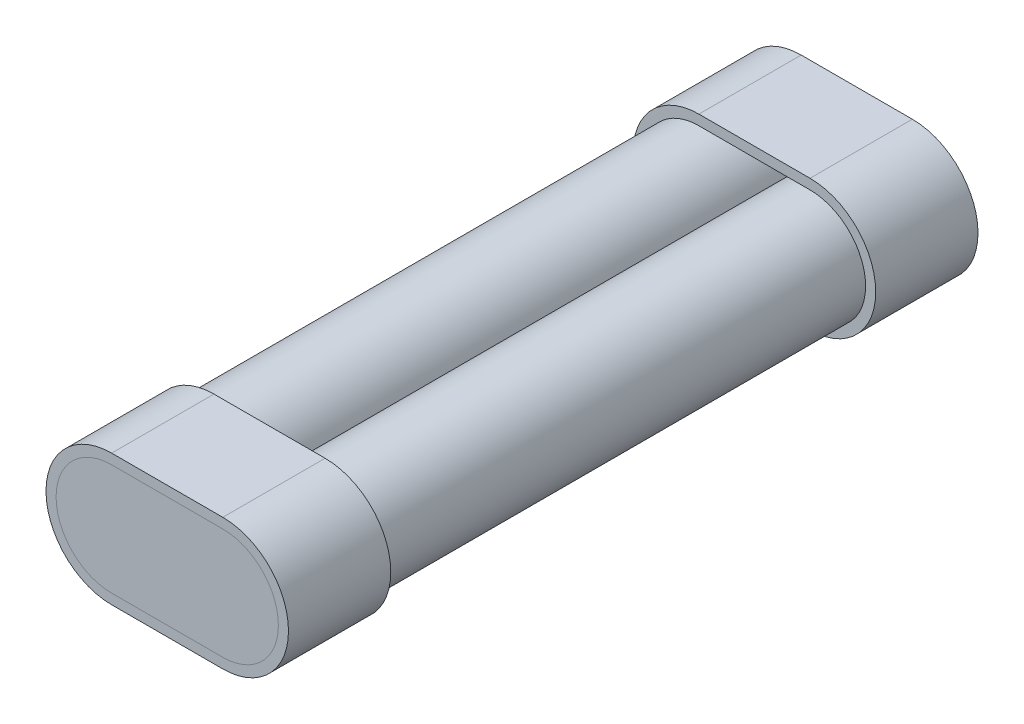
from build123d import *

# Parameters (mm, degrees)
ESQUISSE1_R              = 11
BOSS_EXTRU_2_DEPTH       = 132.5
BOSS_EXTRU_2_2_DEPTH     = 132.5
BOSS_EXTRU_8_DEPTH       = 2
BOSS_EXTRU_8_DEPTH_BACK  = 18.25
BOSS_EXTRU_29_DEPTH      = 2
BOSS_EXTRU_33_DEPTH      = 2
BOSS_EXTRU_33_DEPTH_BACK = 18.25
BOSS_EXTRU_34_DEPTH      = 2


with BuildPart() as part:
    # Esquisse1 → Boss.-Extru.2 (new body)
    with BuildSketch(Plane.XY):
        with Locations((-11, 0)):
            Circle(ESQUISSE1_R)
    extrude(amount=-BOSS_EXTRU_2_DEPTH)


with BuildPart() as body_2:
    # Esquisse1 → Boss.-Extru.2 2 (new body)
    with BuildSketch(Plane.XY):
        with Locations((11, 0)):
            Circle(ESQUISSE1_R)
    extrude(amount=-BOSS_EXTRU_2_2_DEPTH)


with BuildPart() as body_3:
    # Esquisse1_5 → Boss.-Extru.8 (new, two sides: drawn at the far end of the back side and taken through both)
    with BuildSketch(Plane.XY.offset(-BOSS_EXTRU_8_DEPTH_BACK)):
        with BuildLine():
            Line((11, 13), (-11, 13))
            ThreePointArc((-11, 13), (-24, 0), (-11, -13))
            Line((-11, -13), (11, -13))
            ThreePointArc((11, -13), (24, 0), (11, 13))
        make_face()
        with BuildLine():
            Line((11, -11), (-11, -11))
            ThreePointArc((-11, -11), (-22, 0), (-11, 11))
            Line((-11, 11), (11, 11))
            ThreePointArc((11, 11), (18.778174593, 7.778174593), (22, 0))
            ThreePointArc((22, 0), (18.778174593, -7.778174593), (11, -11))
        make_face(mode=Mode.SUBTRACT)
    extrude(amount=BOSS_EXTRU_8_DEPTH + BOSS_EXTRU_8_DEPTH_BACK)


with BuildPart() as body_4:
    # Esquisse1_6 → Boss.-Extru.29 (new body)
    with BuildSketch(Plane.XY):
        with BuildLine():
            Line((-11, -11), (11, -11))
            ThreePointArc((11, -11), (22, 0), (11, 11))
            Line((11, 11), (-11, 11))
            ThreePointArc((-11, 11), (-22, 0), (-11, -11))
        make_face()
    extrude(amount=BOSS_EXTRU_29_DEPTH)


with BuildPart() as body_5:
    # Esquisse8 → Boss.-Extru.33 (new, two sides: drawn at the far end of the back side and taken through both)
    with BuildSketch(Plane(origin=(0, 0, -132.5), x_dir=(-1, 0, 0), z_dir=(0, 0, -1)).offset(-BOSS_EXTRU_33_DEPTH_BACK)):
        with BuildLine():
            Line((11, 13), (-11, 13))
            ThreePointArc((-11, 13), (-24, 0), (-11, -13))
            Line((-11, -13), (11, -13))
            ThreePointArc((11, -13), (24, 0), (11, 13))
        make_face()
        with BuildLine():
            Line((11, -11), (-11, -11))
            ThreePointArc((-11, -11), (-22, 0), (-11, 11))
            Line((-11, 11), (11, 11))
            ThreePointArc((11, 11), (18.778174593, 7.778174593), (22, 0))
            ThreePointArc((22, 0), (18.778174593, -7.778174593), (11, -11))
        make_face(mode=Mode.SUBTRACT)
    extrude(amount=BOSS_EXTRU_33_DEPTH + BOSS_EXTRU_33_DEPTH_BACK)


with BuildPart() as body_6:
    # Esquisse8_3 → Boss.-Extru.34 (new body)
    with BuildSketch(Plane(origin=(0, 0, -132.5), x_dir=(-1, 0, 0), z_dir=(0, 0, -1))):
        with BuildLine():
            Line((-11, -11), (11, -11))
            ThreePointArc((11, -11), (22, 0), (11, 11))
            Line((11, 11), (-11, 11))
            ThreePointArc((-11, 11), (-22, 0), (-11, -11))
        make_face()
    extrude(amount=BOSS_EXTRU_34_DEPTH)


solid = Compound([part.part, body_2.part, body_3.part, body_4.part, body_5.part, body_6.part])
